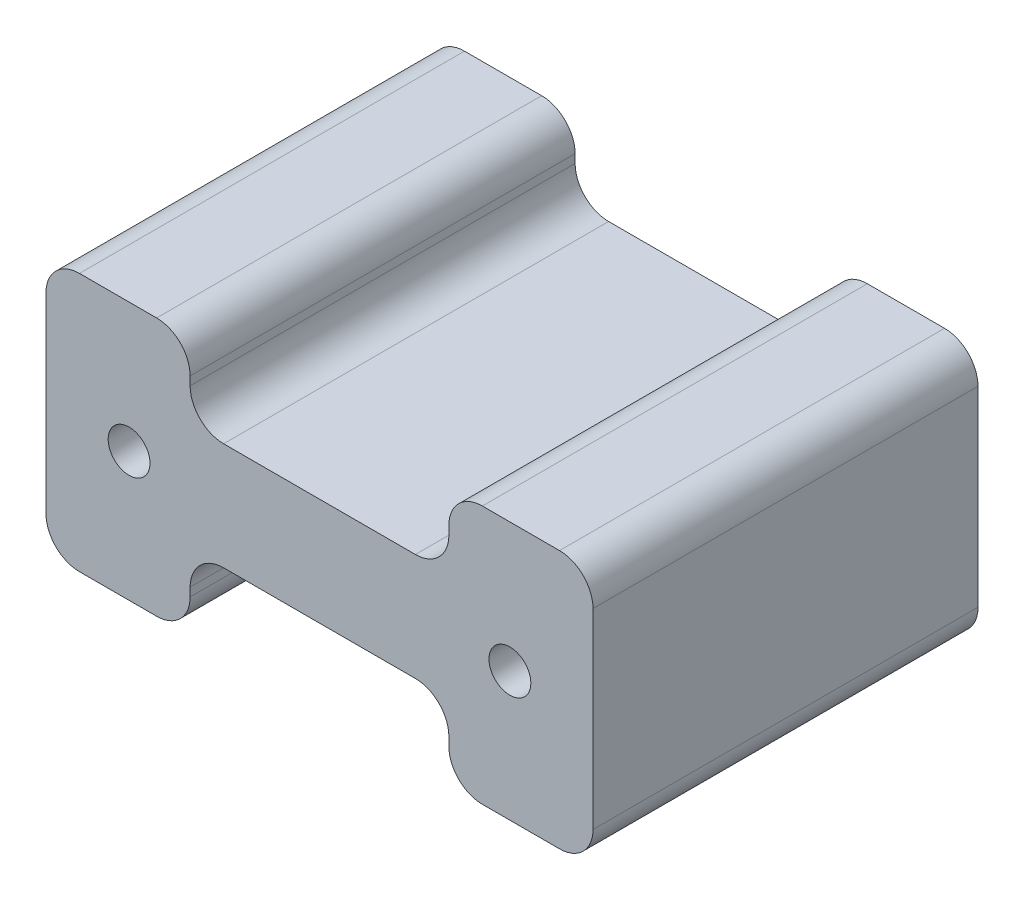
from build123d import *

# Parameters (mm, degrees)
SKETCH_1_W          = 32.677388302
SKETCH_1_H          = 15.432977872
EXTRUDE_1_DEPTH     = 23
SKETCH_2_R          = 1.25
SKETCH_2_W          = 15.458117654
SKETCH_2_H          = 9.017063249
CUT_EXTRUDE_1_DEPTH = 24
FILLET_1_R          = 2
FILLET_2_R          = 2


with BuildPart() as part:
    # 草图1 → 凸台-拉伸1 (new body)
    with BuildSketch(Plane.XY):
        with Locations((-3.726697353, 26.358574689)):
            Rectangle(SKETCH_1_W, SKETCH_1_H)
    extrude(amount=-EXTRUDE_1_DEPTH)

    # 草图2 → 切除-拉伸1 (cut, through all)
    with BuildSketch(Plane.XY):
        with Locations((-15.101697353, 26.358574689)):
            Circle(SKETCH_2_R)
        with Locations((7.648302647, 26.358574689)):
            Circle(SKETCH_2_R)
        with Locations((-3.726697353, 18.642085753)):
            Rectangle(SKETCH_2_W, SKETCH_2_H)
        with Locations((-3.726697353, 34.075063626)):
            Rectangle(SKETCH_2_W, SKETCH_2_H)
    extrude(amount=-CUT_EXTRUDE_1_DEPTH, mode=Mode.SUBTRACT)

    # 圆角1
    fillet_1_edges = [part.edges().sort_by_distance(p)[0] for p in [
        (12.611996798, 18.642085753, -11.5),
        (-20.065391504, 18.642085753, -11.5),
        (-20.065391504, 34.075063625, -11.5),
        (12.611996798, 34.075063625, -11.5),
    ]]
    fillet(fillet_1_edges, radius=FILLET_1_R)

    # 圆角2
    fillet_2_edges = [part.edges().sort_by_distance(p)[0] for p in [
        (-11.45575618, 34.075063625, -11.5),
        (4.002361474, 34.075063625, -11.5),
        (-11.45575618, 29.566532001, -11.5),
        (4.002361474, 29.566532001, -11.5),
        (4.002361474, 18.642085753, -11.5),
        (-11.45575618, 18.642085753, -11.5),
        (4.002361474, 23.150617378, -11.5),
        (-11.45575618, 23.150617378, -11.5),
    ]]
    fillet(fillet_2_edges, radius=FILLET_2_R)


solid = part.part
